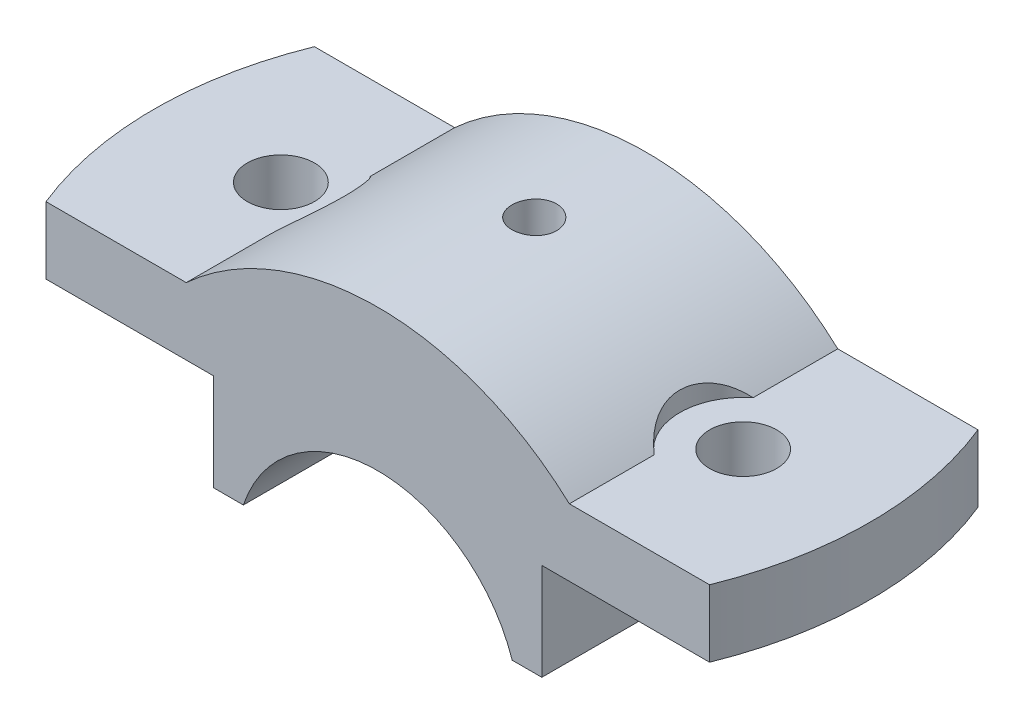
from build123d import *

# Parameters (mm, degrees)
BOSS_EXTRUDE1_DEPTH    = 18
CUT_EXTRUDE1_DEPTH     = 23
F_12_0MM_DOWEL_HOLE3_D = 9
CUT_EXTRUDE5_DEPTH     = 36


with BuildPart() as part:
    # Sketch1 → Boss-Extrude1 (new body, symmetric)
    with BuildSketch(Plane.XY):
        with BuildLine():
            Line((18.027756377, 6), (22, 6))
            Line((22, 6), (22, 19))
            Line((22, 19), (50, 19))
            Line((50, 19), (50, 28))
            Line((50, 28), (25.690465157, 28))
            ThreePointArc((25.690465157, 28), (0, 38), (-25.690465157, 28))
            Line((-25.690465157, 28), (-50, 28))
            Line((-50, 28), (-50, 19))
            Line((-50, 19), (-22, 19))
            Line((-22, 19), (-22, 6))
            Line((-22, 6), (-18.027756377, 6))
            ThreePointArc((-18.027756377, 6), (0, 19), (18.027756377, 6))
        make_face()
    extrude(amount=BOSS_EXTRUDE1_DEPTH, both=True)

    # Sketch3 → Cut-Extrude1 (cut, through all)
    with BuildSketch(Plane(origin=(0, 28, 0), x_dir=(1, 0, 0), z_dir=(0, 1, 0))):
        with BuildLine():
            Line((-44.497190923, 18), (-50, 18))
            Line((-50, 18), (-50, -18))
            Line((-50, -18), (-44.497190923, -18))
            ThreePointArc((-44.497190923, -18), (-48, 0), (-44.497190923, 18))
        make_face()
    cut_extrude1 = extrude(amount=-CUT_EXTRUDE1_DEPTH, mode=Mode.SUBTRACT)

    # Ø12.0mm Dowel Hole3 (through all)
    with Locations(Plane(origin=(0, 28, 0), x_dir=(1, 0, 0), z_dir=(0, 1, 0))):
        with Locations((-31, 0)):
            f_12_0mm_dowel_hole3 = Hole(F_12_0MM_DOWEL_HOLE3_D / 2)

    # Sketch17 → Cut-Extrude5 (cut)
    with BuildSketch(Plane(origin=(0, 28, 0), x_dir=(1, 0, 0), z_dir=(0, 1, 0))):
        with BuildLine():
            Line((-25.690465157, -6.637683312), (-25.690465157, 6.637683312))
            ThreePointArc((-25.690465157, 6.637683312), (-22.5, 0), (-25.690465157, -6.637683312))
        make_face()
    cut_extrude5 = extrude(amount=CUT_EXTRUDE5_DEPTH, mode=Mode.SUBTRACT)

    # Sketch20 → CBORE for M6 Hex Head Bolt1 (revolve, cut)
    with BuildSketch(Plane(origin=(0, 38, -2.983943356), x_dir=(0, 0, 1), z_dir=(1, 0, 0))):
        Polygon((0, 0), (0, 32), (2.5, 32), (2.5, 13.495), (2.995, 13), (3, 13), (3, 0), align=None)
    cbore_for_m6_hex_head_bolt1 = revolve(axis=Axis((0, 44.35, -2.983943356), (0, -1, 0)), mode=Mode.SUBTRACT)

    # Mirror1: Cut-Extrude1, Ø12.0mm Dowel Hole3, Cut-Extrude5, CBORE for M6 Hex Head Bolt1 across plane
    add(cut_extrude1.mirror(Plane(origin=(0, 0, 0), x_dir=(0, 0, 1), z_dir=(1, 0, 0))), mode=Mode.SUBTRACT)
    add(f_12_0mm_dowel_hole3.mirror(Plane(origin=(0, 0, 0), x_dir=(0, 0, 1), z_dir=(1, 0, 0))), mode=Mode.SUBTRACT)
    add(cut_extrude5.mirror(Plane(origin=(0, 0, 0), x_dir=(0, 0, 1), z_dir=(1, 0, 0))), mode=Mode.SUBTRACT)
    add(cbore_for_m6_hex_head_bolt1.mirror(Plane(origin=(0, 0, 0), x_dir=(0, 0, 1), z_dir=(1, 0, 0))), mode=Mode.SUBTRACT)


solid = part.part
